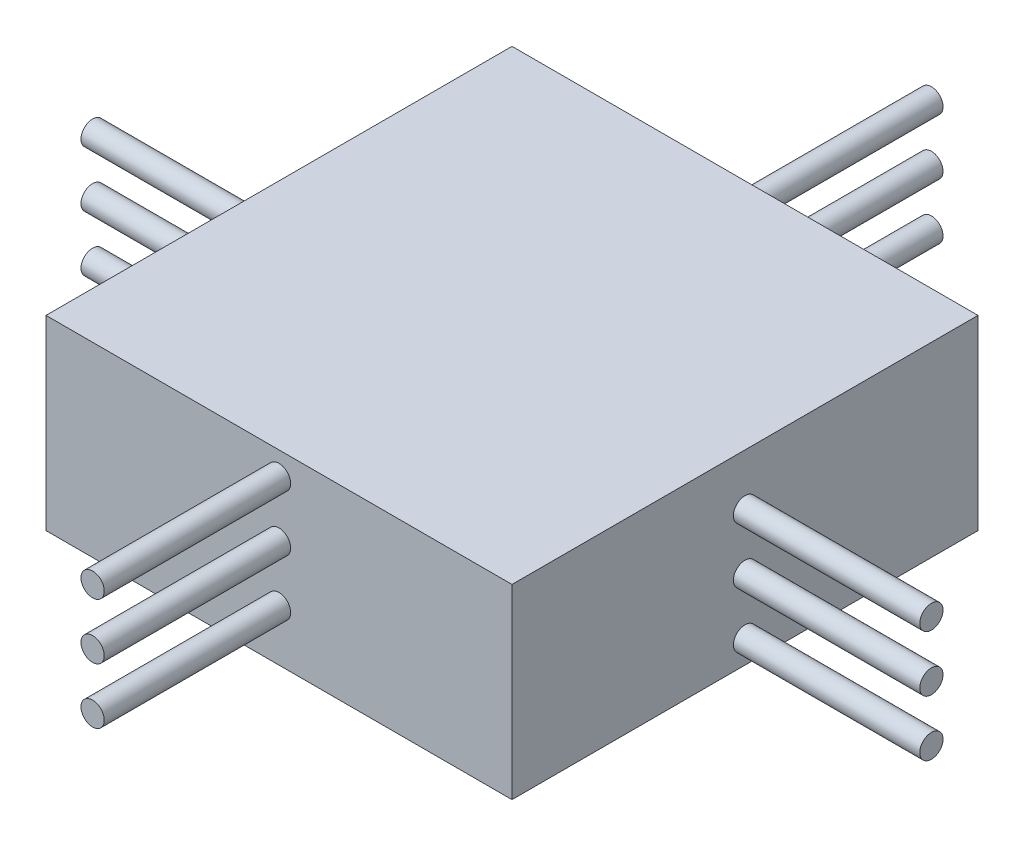
from build123d import *

# Parameters (mm, degrees)
SKETCH1_W                  = 50
SKETCH1_H                  = 50
BOSS_EXTRUDE1_DEPTH        = 20
SKETCH2_R                  = 1.25
BOSS_EXTRUDE2_DEPTH        = 20
BOSS_EXTRUDE2_DEPTH_BACK   = 70
BOSS_EXTRUDE2_2_DEPTH      = 20
BOSS_EXTRUDE2_2_DEPTH_BACK = 70
BOSS_EXTRUDE2_3_DEPTH      = 20
BOSS_EXTRUDE2_3_DEPTH_BACK = 70
SKETCH3_R                  = 1.25
BOSS_EXTRUDE3_DEPTH        = 20
BOSS_EXTRUDE3_DEPTH_BACK   = 70
BOSS_EXTRUDE3_2_DEPTH      = 20
BOSS_EXTRUDE3_2_DEPTH_BACK = 70
BOSS_EXTRUDE3_3_DEPTH      = 20
BOSS_EXTRUDE3_3_DEPTH_BACK = 70


with BuildPart() as part:
    # Sketch1 → Boss-Extrude1 (new body)
    with BuildSketch(Plane(origin=(0, 0, 0), x_dir=(1, 0, 0), z_dir=(0, 1, 0))):
        Rectangle(SKETCH1_W, SKETCH1_H)
    extrude(amount=BOSS_EXTRUDE1_DEPTH)


with BuildPart() as body_2:
    # Sketch2 → Boss-Extrude2 (new body, two sides)
    with BuildSketch(Plane.XY.offset(25)) as boss_extrude2_sk:
        with Locations((0, 17.5)):
            Circle(SKETCH2_R)
    extrude(amount=BOSS_EXTRUDE2_DEPTH)
    extrude(boss_extrude2_sk.sketch, amount=-BOSS_EXTRUDE2_DEPTH_BACK)


with BuildPart() as body_3:
    # Sketch2 → Boss-Extrude2 2 (new body, two sides)
    with BuildSketch(Plane.XY.offset(25)) as boss_extrude2_2_sk:
        with Locations((0, 11.5)):
            Circle(SKETCH2_R)
    extrude(amount=BOSS_EXTRUDE2_2_DEPTH)
    extrude(boss_extrude2_2_sk.sketch, amount=-BOSS_EXTRUDE2_2_DEPTH_BACK)


with BuildPart() as body_4:
    # Sketch2 → Boss-Extrude2 3 (new body, two sides)
    with BuildSketch(Plane.XY.offset(25)) as boss_extrude2_3_sk:
        with Locations((0, 5.5)):
            Circle(SKETCH2_R)
    extrude(amount=BOSS_EXTRUDE2_3_DEPTH)
    extrude(boss_extrude2_3_sk.sketch, amount=-BOSS_EXTRUDE2_3_DEPTH_BACK)


with BuildPart() as body_5:
    # Sketch3 → Boss-Extrude3 (new body, two sides)
    with BuildSketch(Plane(origin=(25, 0, 0), x_dir=(0, 0, -1), z_dir=(1, 0, 0))) as boss_extrude3_sk:
        with Locations((0, 14.5)):
            Circle(SKETCH3_R)
    extrude(amount=BOSS_EXTRUDE3_DEPTH)
    extrude(boss_extrude3_sk.sketch, amount=-BOSS_EXTRUDE3_DEPTH_BACK)


with BuildPart() as body_6:
    # Sketch3 → Boss-Extrude3 2 (new body, two sides)
    with BuildSketch(Plane(origin=(25, 0, 0), x_dir=(0, 0, -1), z_dir=(1, 0, 0))) as boss_extrude3_2_sk:
        with Locations((0, 8.5)):
            Circle(SKETCH3_R)
    extrude(amount=BOSS_EXTRUDE3_2_DEPTH)
    extrude(boss_extrude3_2_sk.sketch, amount=-BOSS_EXTRUDE3_2_DEPTH_BACK)


with BuildPart() as body_7:
    # Sketch3 → Boss-Extrude3 3 (new body, two sides)
    with BuildSketch(Plane(origin=(25, 0, 0), x_dir=(0, 0, -1), z_dir=(1, 0, 0))) as boss_extrude3_3_sk:
        with Locations((0, 2.5)):
            Circle(SKETCH3_R)
    extrude(amount=BOSS_EXTRUDE3_3_DEPTH)
    extrude(boss_extrude3_3_sk.sketch, amount=-BOSS_EXTRUDE3_3_DEPTH_BACK)


solid = Compound([part.part, body_2.part, body_3.part, body_4.part, body_5.part, body_6.part, body_7.part])
